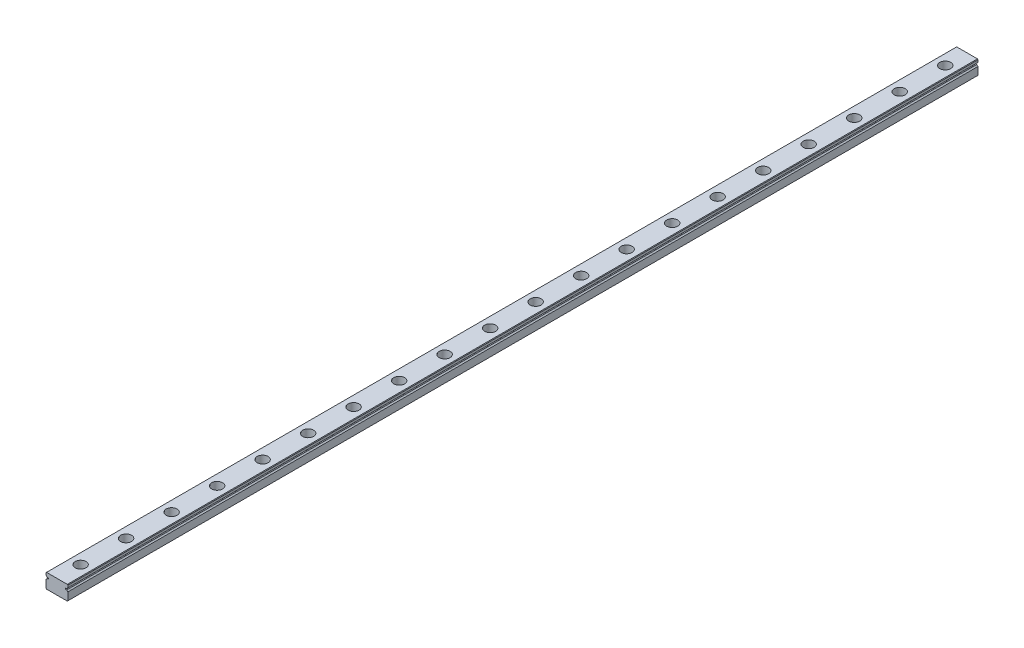
from build123d import *

# Parameters (mm, degrees)
EXTRUDE_1_DEPTH        = 500
SKETCH_2_R             = 3
SKETCH_2_R_2           = 1.75
CUT_EXTRUDE_1_DEPTH    = 4.5
SKETCH_2_2_R           = 1.75
CUT_EXTRUDE_2_DEPTH    = 501.099990002
PATTERN_LINEAR_1_COUNT = 20
PATTERN_LINEAR_1_PITCH = 25


with BuildPart() as part:
    # Эскиз1 → Бобышка-Вытянуть1 (new body)
    with BuildSketch(Plane.XY):
        with BuildLine():
            Line((-6, 3.7), (-5.7, 4))
            Line((-5.7, 4), (5.7, 4))
            Line((5.7, 4), (6, 3.7))
            Line((6, 3.7), (6, 2.451013544))
            ThreePointArc((6, 2.451013544), (5.597935912, 2.202976267), (5.354599002, 1.798050138))
            Line((5.354599002, 1.798050138), (4.643514056, 1.798050138))
            Line((4.643514056, 1.798050138), (4.643514056, 1.201949862))
            Line((4.643514056, 1.201949862), (5.354599002, 1.201949862))
            ThreePointArc((5.354599002, 1.201949862), (5.597935912, 0.797023733), (6, 0.548986456))
            Line((6, 0.548986456), (6, -3.7))
            Line((6, -3.7), (5.7, -4))
            Line((5.7, -4), (-5.7, -4))
            Line((-5.7, -4), (-6, -3.7))
            Line((-6, -3.7), (-6, 0.548986456))
            ThreePointArc((-6, 0.548986456), (-5.597935912, 0.797023733), (-5.354599002, 1.201949862))
            Line((-5.354599002, 1.201949862), (-4.643514056, 1.201949862))
            Line((-4.643514056, 1.201949862), (-4.643514056, 1.798050138))
            Line((-4.643514056, 1.798050138), (-5.354599002, 1.798050138))
            ThreePointArc((-5.354599002, 1.798050138), (-5.597935912, 2.202976267), (-6, 2.451013544))
            Line((-6, 2.451013544), (-6, 3.7))
        make_face()
    extrude(amount=EXTRUDE_1_DEPTH)

    # Эскиз2 → Вырез-Вытянуть1 (cut)
    with BuildSketch(Plane(origin=(0, 4, 0), x_dir=(1, 0, 0), z_dir=(0, 1, 0))):
        with Locations((0, -12)):
            Circle(SKETCH_2_R)
        with Locations((0, -12)):
            Circle(SKETCH_2_R_2, mode=Mode.SUBTRACT)
    cut_extrude_1 = extrude(amount=-CUT_EXTRUDE_1_DEPTH, mode=Mode.SUBTRACT)

    # Эскиз2<2> → Вырез-Вытянуть2 (cut, through all)
    with BuildSketch(Plane(origin=(0, 4, 0), x_dir=(1, 0, 0), z_dir=(0, 1, 0))):
        with Locations((0, -12)):
            Circle(SKETCH_2_2_R)
    cut_extrude_2 = extrude(amount=-CUT_EXTRUDE_2_DEPTH, mode=Mode.SUBTRACT)

    # Линейный массив1: Вырез-Вытянуть1, Вырез-Вытянуть2 ×20
    with Locations(*[(0, 0, i * PATTERN_LINEAR_1_PITCH) for i in range(1, PATTERN_LINEAR_1_COUNT)]):
        add(cut_extrude_1, mode=Mode.SUBTRACT)
        add(cut_extrude_2, mode=Mode.SUBTRACT)


solid = part.part
